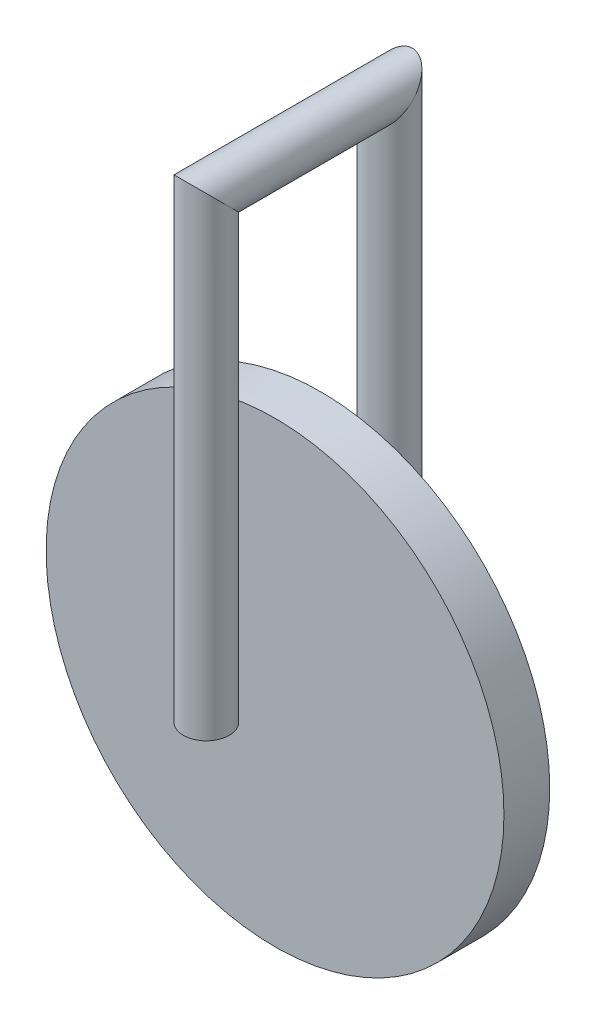
from build123d import *

# Parameters (mm, degrees)
SKETCH1_R           = 50
BOSS_EXTRUDE1_DEPTH = 5
SWEEP1_PROFILE_R    = 5


with BuildPart() as part:
    # Sketch1 → Boss-Extrude1 (new, symmetric)
    with BuildSketch(Plane.XY):
        Circle(SKETCH1_R)
    extrude(amount=BOSS_EXTRUDE1_DEPTH, both=True)


with BuildPart() as body_2:
    # Sweep1: sweep along a path in Sketch5
    with BuildLine(Plane(origin=(0, 0, 0), x_dir=(0, 0, -1), z_dir=(1, 0, 0))) as sweep1_path:
        Line((-20, 0), (-20, 100))
        Line((-20, 100), (20, 100))
        Line((20, 100), (20, 0))
    # Sweep1 profile (on start of the path) → Sweep1 (sweep)
    with BuildSketch(Plane(origin=(0, 0, 20), x_dir=(0, 0, 1), z_dir=(0, 1, 0))):
        Circle(SWEEP1_PROFILE_R)
    sweep(path=sweep1_path.line, transition=Transition.RIGHT)


solid = Compound([part.part, body_2.part])
